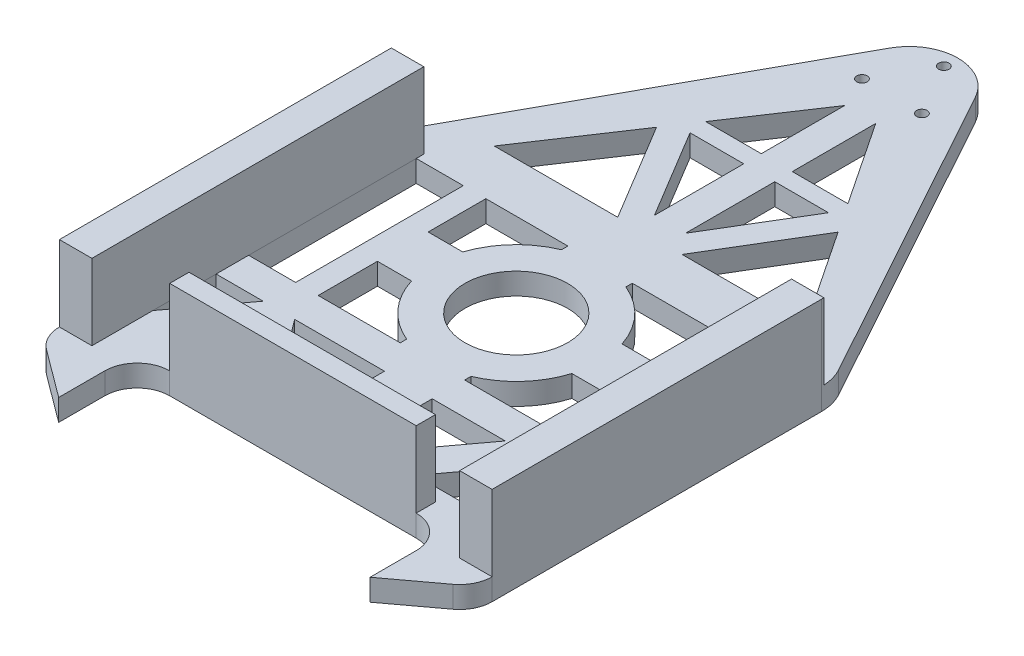
from build123d import *

# Parameters (mm, degrees)
SKETCH1_R            = 47.5
BOSS_EXTRUDE6_DEPTH  = 20
FILLET2_R            = 30
SKETCH3_W            = 227.888974491
SKETCH3_H            = 17.82820952
SKETCH3_W_2          = 30.029703607
SKETCH3_H_2          = 306.819916415
SKETCH3_W_3          = 30
BOSS_EXTRUDE12_DEPTH = 70
FILLET3_R            = 45
FILLET4_R            = 45
SKETCH4_R            = 4.852465173
CUT_EXTRUDE2_DEPTH   = 21


with BuildPart() as part:
    # Sketch1 → Boss-Extrude6 (new body)
    with BuildSketch(Plane(origin=(0, 0, 0), x_dir=(1, 0, 0), z_dir=(0, 1, 0))):
        Polygon((-324.500042801, -72.630227613), (-324.500042801, 0), (-36.61106831, 0), (-36.61106831, -72.630227613), (19.444444444, -30.98937664), (19.444444444, 0), (19.444444444, 300), (-180.555555556, 662.976241067), (-380.555555556, 300), (-380.555555556, 0), (-380.555555556, -30.98937664), align=None)
        Polygon((-264.055692307, 30), (-320.898350202, 30), (-292.477021255, 68.259836918), align=None, mode=Mode.SUBTRACT)
        Polygon((-350.555555556, 40.384990781), (-350.555555556, 98.955926659), (-307.046121917, 98.955926659), align=None, mode=Mode.SUBTRACT)
        Polygon((-194.895952536, 18.381237109), (-218.052993309, 18.381237109), (-277.907920592, 98.955926659), (-194.895952536, 98.955926659), align=None, mode=Mode.SUBTRACT)
        Polygon((-307.046121917, 128.955926659), (-350.555555556, 128.955926659), (-350.555555556, 178.791030317), (-350.555555556, 221.457829656), (-350.555555556, 283.955926659), (-307.046121917, 283.955926659), (-307.046121917, 221.457829656), (-307.046121917, 178.791030317), align=None, mode=Mode.SUBTRACT)
        with BuildLine():
            Line((-210.32776095, 128.955926659), (-286.18247229, 128.955926659))
            Line((-286.18247229, 128.955926659), (-286.18247229, 183.722078004))
            Line((-286.18247229, 183.722078004), (-254.646190087, 183.722078004))
            ThreePointArc((-254.646190087, 183.722078004), (-237.937656941, 154.364234033), (-210.32776095, 134.902689235))
            Line((-210.32776095, 134.902689235), (-210.32776095, 128.955926659))
        make_face(mode=Mode.SUBTRACT)
        with BuildLine():
            Line((-286.18247229, 230.610640855), (-286.18247229, 283.955926659))
            Line((-286.18247229, 283.955926659), (-210.32776095, 283.955926659))
            Line((-210.32776095, 283.955926659), (-210.32776095, 278.009164084))
            ThreePointArc((-210.32776095, 278.009164084), (-237.43400989, 259.09708387), (-254.195217302, 230.610640855))
            Line((-254.195217302, 230.610640855), (-286.18247229, 230.610640855))
        make_face(mode=Mode.SUBTRACT)
        with Locations((-180.555555556, 206.455926659)):
            Circle(SKETCH1_R, mode=Mode.SUBTRACT)
        Polygon((-143.058117802, 18.381237109), (-150.783350161, 18.381237109), (-150.783350161, 98.955926659), (-83.203190519, 98.955926659), align=None, mode=Mode.SUBTRACT)
        Polygon((-68.634089856, 68.259836918), (-40.212760909, 30), (-97.055418804, 30), align=None, mode=Mode.SUBTRACT)
        Polygon((-10.555555556, 98.955926659), (-10.555555556, 40.384990781), (-54.064989194, 98.955926659), align=None, mode=Mode.SUBTRACT)
        with BuildLine():
            Line((-150.783350161, 128.955926659), (-150.783350161, 134.902689235))
            ThreePointArc((-150.783350161, 134.902689235), (-123.17345417, 154.364234033), (-106.464921024, 183.722078004))
            Line((-106.464921024, 183.722078004), (-74.928638821, 183.722078004))
            Line((-74.928638821, 183.722078004), (-74.928638821, 128.955926659))
            Line((-74.928638821, 128.955926659), (-150.783350161, 128.955926659))
        make_face(mode=Mode.SUBTRACT)
        with BuildLine():
            ThreePointArc((-106.915893809, 230.610640855), (-123.677101221, 259.09708387), (-150.783350161, 278.009164084))
            Line((-150.783350161, 278.009164084), (-150.783350161, 283.955926659))
            Line((-150.783350161, 283.955926659), (-74.928638821, 283.955926659))
            Line((-74.928638821, 283.955926659), (-74.928638821, 230.610640855))
            Line((-74.928638821, 230.610640855), (-106.915893809, 230.610640855))
        make_face(mode=Mode.SUBTRACT)
        Polygon((-10.555555556, 178.791030317), (-10.555555556, 128.955926659), (-54.064989194, 128.955926659), (-54.064989194, 178.791030317), (-54.064989194, 221.457829656), (-54.064989194, 283.955926659), (-10.555555556, 283.955926659), (-10.555555556, 221.457829656), align=None, mode=Mode.SUBTRACT)
        Polygon((-210.32776095, 330), (-324.500042801, 330), (-264.477795432, 420.033371054), align=None, mode=Mode.SUBTRACT)
        Polygon((-194.895952536, 348.542048906), (-244.539447118, 431.082553467), (-194.895952536, 431.082553467), align=None, mode=Mode.SUBTRACT)
        Polygon((-246.308768225, 447.286911864), (-194.895952536, 524.406135398), (-194.895952536, 447.286911864), align=None, mode=Mode.SUBTRACT)
        Polygon((-96.633315679, 420.033371054), (-36.61106831, 330), (-150.783350161, 330), align=None, mode=Mode.SUBTRACT)
        Polygon((-166.215158575, 431.082553467), (-116.571663993, 431.082553467), (-166.215158575, 348.542048906), align=None, mode=Mode.SUBTRACT)
        Polygon((-166.215158575, 524.406135398), (-114.802342886, 447.286911864), (-166.215158575, 447.286911864), align=None, mode=Mode.SUBTRACT)
    extrude(amount=BOSS_EXTRUDE6_DEPTH)

    # Fillet2
    fillet2_edges = [part.edges().sort_by_distance(p)[0] for p in [
        (19.444444444, 10, 30.98937664),
        (-36.61106831, 10, 0),
        (-324.500042801, 10, 0),
        (-380.555555556, 10, 30.98937664),
    ]]
    fillet(fillet2_edges, radius=FILLET2_R)

    # Sketch3 → Boss-Extrude12 (add)
    with BuildSketch(Plane(origin=(0, 20, 0), x_dir=(1, 0, 0), z_dir=(0, 1, 0))):
        with Locations((-180.555555556, 8.91410476)):
            Rectangle(SKETCH3_W, SKETCH3_H)
        with Locations((-365.540703753, 137.50677266)):
            Rectangle(SKETCH3_W_2, SKETCH3_H_2)
        with Locations((4.444444444, 137.50677266)):
            Rectangle(SKETCH3_W_3, SKETCH3_H_2)
    extrude(amount=BOSS_EXTRUDE12_DEPTH)

    # Fillet3
    fillet3_edges = [part.edges().sort_by_distance(p)[0] for p in [
        (-180.555555556, 10, -662.976241067),
    ]]
    fillet(fillet3_edges, radius=FILLET3_R)

    # Fillet4
    fillet4_edges = [part.edges().sort_by_distance(p)[0] for p in [
        (-380.555555556, 10, -300),
        (19.444444444, 10, -300),
    ]]
    fillet(fillet4_edges, radius=FILLET4_R)

    # Sketch4 → Cut-Extrude2 (cut, through all)
    with BuildSketch(Plane(origin=(0, 20, 0), x_dir=(1, 0, 0), z_dir=(0, 1, 0))):
        with Locations((-180.555555556, 601.729619553)):
            Circle(SKETCH4_R)
        with Locations((-208.268368477, 553.729619553)):
            Circle(SKETCH4_R)
        with Locations((-152.842742634, 553.729619553)):
            Circle(SKETCH4_R)
    extrude(amount=-CUT_EXTRUDE2_DEPTH, mode=Mode.SUBTRACT)


solid = part.part
